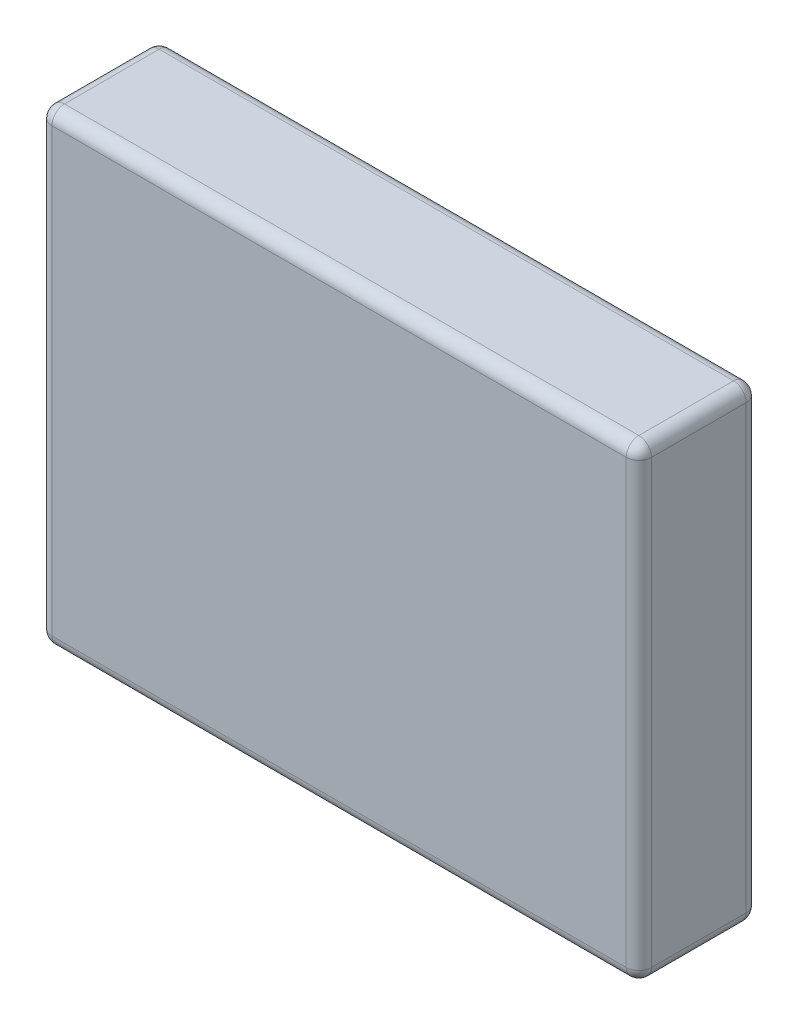
from build123d import *

# Parameters (mm, degrees)
SKETCH_2_W      = 95
SKETCH_2_H      = 74
EXTRUDE_2_DEPTH = 19
FILLET_1_R      = 2


with BuildPart() as part:
    # 草图2 → 凸台-拉伸2 (new body)
    with BuildSketch(Plane.XY):
        Rectangle(SKETCH_2_W, SKETCH_2_H)
    extrude(amount=EXTRUDE_2_DEPTH)

    # 圆角1
    fillet_1_edges = [part.edges().sort_by_distance(p)[0] for p in [
        (47.5, 0, 19),
        (0, 37, 19),
        (-47.5, 0, 19),
        (0, 37, 0),
        (47.5, 0, 0),
        (0, -37, 0),
        (-47.5, 0, 0),
        (-47.5, 37, 9.5),
        (47.5, 37, 9.5),
        (47.5, -37, 9.5),
        (-47.5, -37, 9.5),
        (0, -37, 19),
    ]]
    fillet(fillet_1_edges, radius=FILLET_1_R)


solid = part.part
